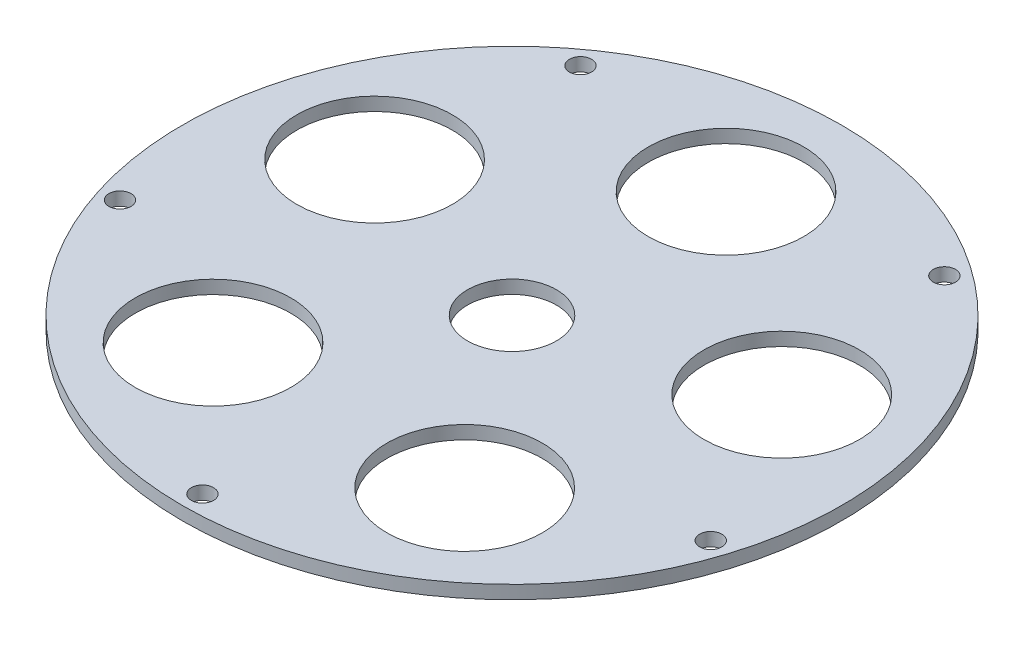
from build123d import *

# Parameters (mm, degrees)
SKETCH1_R           = 74.18267629
BOSS_EXTRUDE2_DEPTH = 3
SKETCH1_4_R         = 17.5
SKETCH1_4_R_2       = 10
CUT_EXTRUDE1_DEPTH  = 4
SKETCH1_5_R         = 2.5
CUT_EXTRUDE2_DEPTH  = 4


with BuildPart() as part:
    # Sketch1 → Boss-Extrude2 (new body)
    with BuildSketch(Plane(origin=(0, 0, 0), x_dir=(1, 0, 0), z_dir=(0, 1, 0))):
        Circle(SKETCH1_R)
    extrude(amount=-BOSS_EXTRUDE2_DEPTH)

    # Sketch1_4 → Cut-Extrude1 (cut)
    with BuildSketch(Plane(origin=(0, 0, 0), x_dir=(1, 0, 0), z_dir=(0, 1, 0))):
        with Locations((0, 48.18267629)):
            Circle(SKETCH1_4_R)
        with Locations((45.824448258, 14.889265808)):
            Circle(SKETCH1_4_R)
        with Locations((28.321066539, -38.980603953)):
            Circle(SKETCH1_4_R)
        with Locations((-28.321066539, -38.980603953)):
            Circle(SKETCH1_4_R)
        with Locations((-45.824448258, 14.889265808)):
            Circle(SKETCH1_4_R)
        Circle(SKETCH1_4_R_2)
    extrude(amount=-CUT_EXTRUDE1_DEPTH, mode=Mode.SUBTRACT)

    # Sketch1_5 → Cut-Extrude2 (cut)
    with BuildSketch(Plane(origin=(0, 0, 0), x_dir=(1, 0, 0), z_dir=(0, 1, 0))):
        with Locations((40.958449464, 56.374469332)):
            Circle(SKETCH1_5_R)
        with Locations((66.272163358, -21.533131187)):
            Circle(SKETCH1_5_R)
        with Locations((0, -69.68267629)):
            Circle(SKETCH1_5_R)
        with Locations((-66.605033139, -21.641287135)):
            Circle(SKETCH1_5_R)
        with Locations((-40.958449464, 56.374469332)):
            Circle(SKETCH1_5_R)
    extrude(amount=-CUT_EXTRUDE2_DEPTH, mode=Mode.SUBTRACT)


solid = part.part
